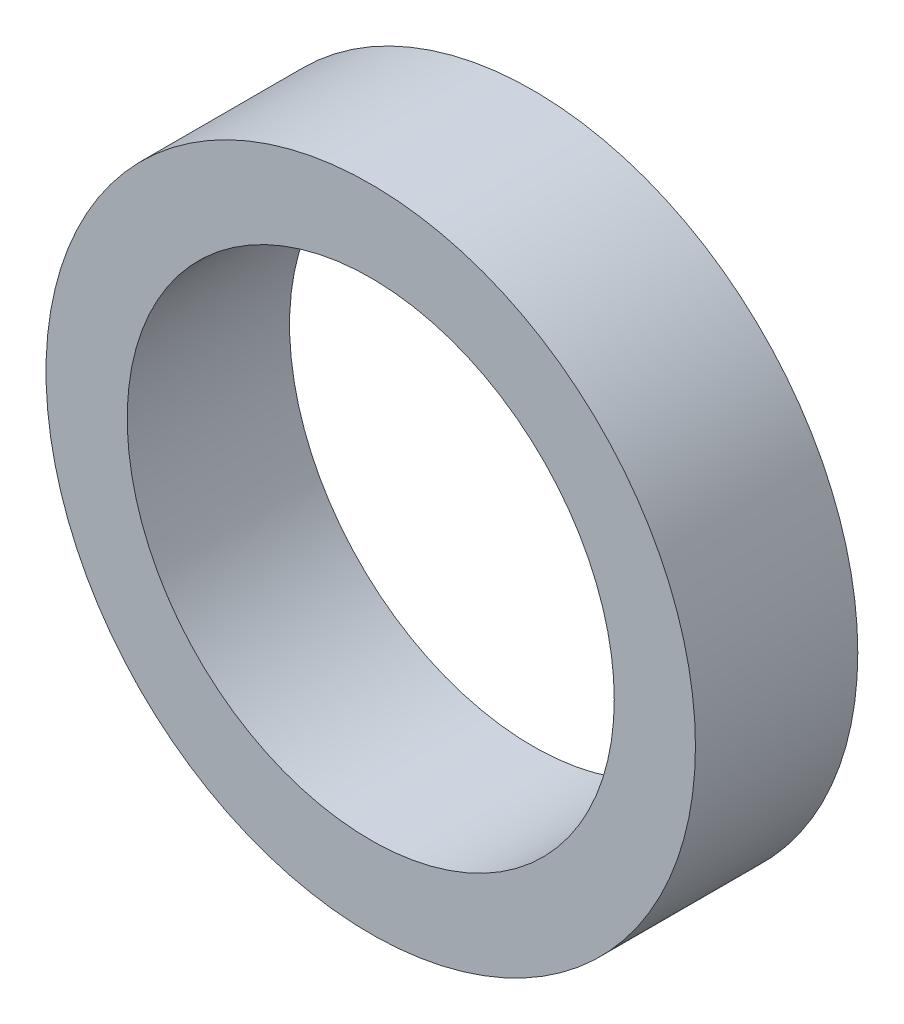
from build123d import *

# Parameters (mm, degrees)
SKETCH1_R           = 8
SKETCH1_R_2         = 6
BOSS_EXTRUDE1_DEPTH = 4


with BuildPart() as part:
    # Sketch1 → Boss-Extrude1 (new body)
    with BuildSketch(Plane.XY):
        Circle(SKETCH1_R)
        Circle(SKETCH1_R_2, mode=Mode.SUBTRACT)
    extrude(amount=BOSS_EXTRUDE1_DEPTH)


solid = part.part
